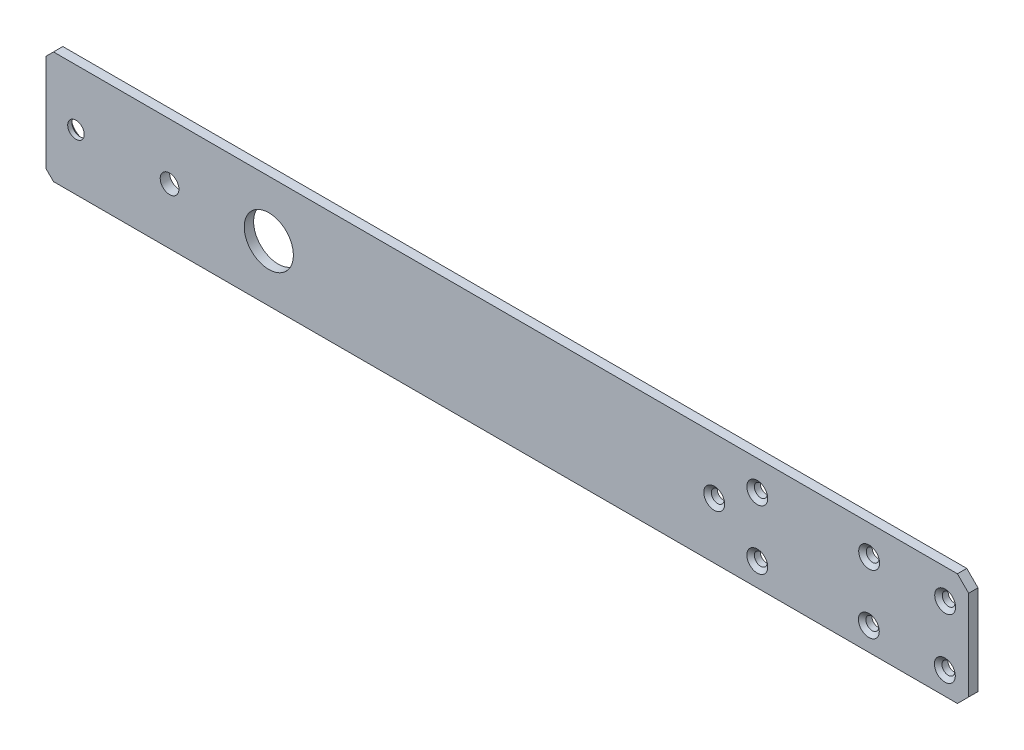
from build123d import *

# Parameters (mm, degrees)
SKETCH1_R                                         = 8.334375
BOSS_EXTRUDE1_DEPTH                               = 1.5875
F_6_CLEARANCE_HOLE3_D                             = 4.3053
CUT_EXTRUDE1_DEPTH                                = 4.175
CHAMFER1_SIZE                                     = 3.81
CSK_FOR_6_FLAT_HEAD_MACHINE_SCREW_100_D           = 4.3053
CSK_FOR_6_FLAT_HEAD_MACHINE_SCREW_100_CSINK_D     = 7.0866
CSK_FOR_6_FLAT_HEAD_MACHINE_SCREW_100_CSINK_ANGLE = 100
SKETCH14_W                                        = 50.8
SKETCH14_H                                        = 38.1
BOSS_EXTRUDE2_DEPTH                               = 3.175
CHAMFER2_SIZE                                     = 2.54
F_1_4_0_25_DIAMETER_HOLE1_D                       = 6.35


with BuildPart() as part:
    # Sketch1 → Boss-Extrude1 (new body, symmetric)
    with BuildSketch(Plane.XY):
        Polygon((0, 19.05), (-28.575, 19.05), (-28.575, -19.05), (0, -19.05), (247.281942035, -19.05), (254, 19.05), align=None)
        Circle(SKETCH1_R, mode=Mode.SUBTRACT)
    extrude(amount=BOSS_EXTRUDE1_DEPTH, both=True)

    # #6 Clearance Hole3 (through all)
    with Locations(Plane.XY.offset(1.5875)):
        with Locations((229.388701471, 8.923791784), (229.282371239, -11.346798968), (203.503161764, -11.143926969), (203.608782335, 8.991375351), (165.672159691, 8.991375351), (165.672159691, -11.143926969), (151.067159691, 0)):
            Hole(F_6_CLEARANCE_HOLE3_D / 2)

    # Sketch9 → Cut-Extrude1 (cut, through all)
    with BuildSketch(Plane.XY.offset(1.5875)):
        Polygon((254, 19.05), (247.281942035, -19.05), (237.352085197, -19.05), (237.352085197, 19.05), align=None)
    extrude(amount=-CUT_EXTRUDE1_DEPTH, mode=Mode.SUBTRACT)

    # Chamfer1
    chamfer1_edges = [part.edges().sort_by_distance(p)[0] for p in [
        (-28.575, -19.05, 0),
        (-28.575, 19.05, 0),
        (237.352085197, 19.05, 0),
        (237.352085197, -19.05, 0),
    ]]
    chamfer(chamfer1_edges, length=CHAMFER1_SIZE)

    # CSK for #6 Flat Head Machine Screw (100)2 (through all)
    with Locations(Plane.XY.offset(1.5875)):
        with Locations((203.608782335, 8.991375351), (203.503161764, -11.143926969), (229.282371239, -11.346798968), (229.388701471, 8.923791784), (165.672159691, 8.991375351), (165.672159691, -11.143926969), (151.067159691, 0)):
            CounterSinkHole(CSK_FOR_6_FLAT_HEAD_MACHINE_SCREW_100_D / 2, CSK_FOR_6_FLAT_HEAD_MACHINE_SCREW_100_CSINK_D / 2, counter_sink_angle=CSK_FOR_6_FLAT_HEAD_MACHINE_SCREW_100_CSINK_ANGLE)

    # Sketch14 → Boss-Extrude2 (add, through all)
    with BuildSketch(Plane.XY.offset(1.5875)):
        with Locations((-50.165, 0)):
            Rectangle(SKETCH14_W, SKETCH14_H)
    extrude(amount=-BOSS_EXTRUDE2_DEPTH)

    # Chamfer2
    chamfer2_edges = [part.edges().sort_by_distance(p)[0] for p in [
        (-75.565, -19.05, 0),
        (-75.565, 19.05, 0),
    ]]
    chamfer(chamfer2_edges, length=CHAMFER2_SIZE)

    # Sketch16 → CSK for #10 Flat Head Machine Screw (100)1 (revolve, cut)
    with BuildSketch(Plane(origin=(-65.405, 0, -1.5875), x_dir=(0, 1, 0), z_dir=(1, 0, 0))):
        Polygon((0, 0), (0, 3.175), (2.8067, 3.175), (2.8067, 1.747676712), (4.8895, 0), align=None)
    revolve(axis=Axis((-65.405, 0, -7.9375), (0, 0, 1)), mode=Mode.SUBTRACT)

    # 1/4 (0.25) Diameter Hole1 (through all)
    with Locations(Plane(origin=(0, 0, -1.5875), x_dir=(-1, 0, 0), z_dir=(0, 0, -1))):
        with Locations((33.655, 0)):
            Hole(F_1_4_0_25_DIAMETER_HOLE1_D / 2)


solid = part.part
